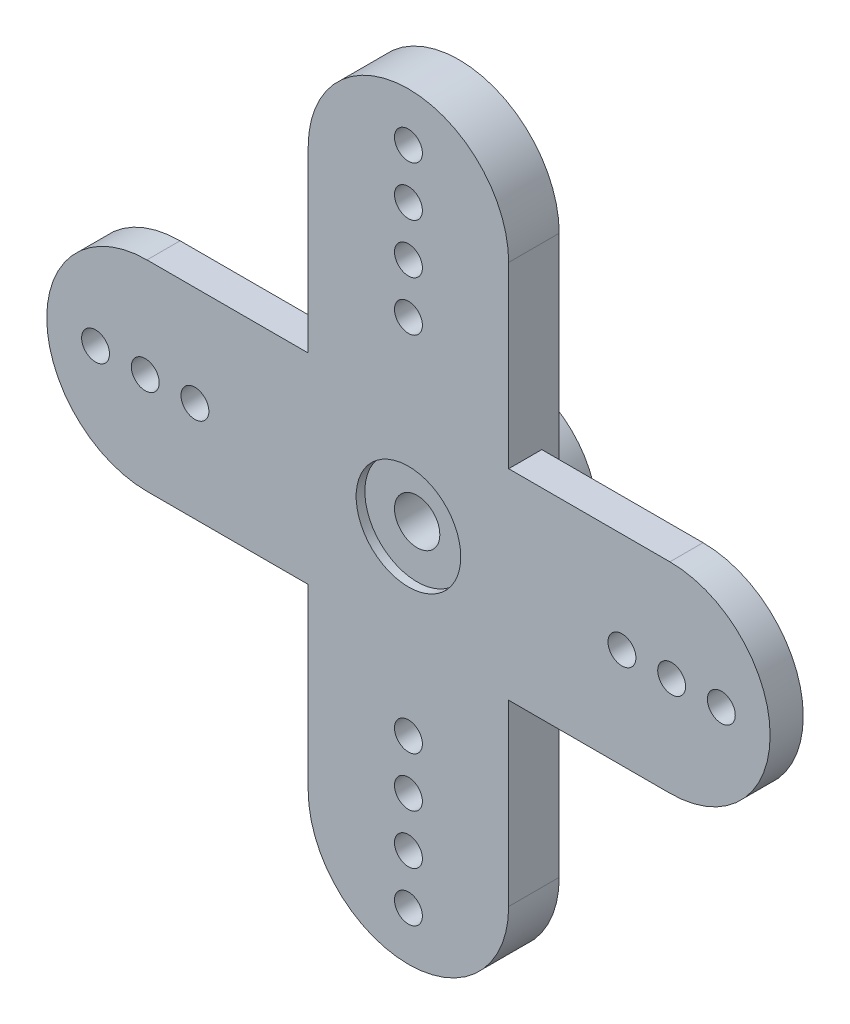
from build123d import *

# Parameters (mm, degrees)
BOSS_EXTRUDE1_DEPTH = 1.9
BOSS_EXTRUDE2_DEPTH = 1
SKETCH3_R           = 3
CUT_EXTRUDE1_DEPTH  = 0.5
SKETCH4_R           = 4.825
SKETCH4_R_2         = 2.775
BOSS_EXTRUDE3_DEPTH = 3.1
SKETCH5_R           = 1.3
CUT_EXTRUDE2_DEPTH  = 3.9
SKETCH6_R           = 0.8
CUT_EXTRUDE4_DEPTH  = 7


with BuildPart() as part:
    # Sketch1 → Boss-Extrude1 (new body)
    with BuildSketch(Plane.XY):
        with BuildLine():
            Line((-5.75, 16), (-5.75, 5.75))
            Line((-5.75, 5.75), (-15, 5.75))
            ThreePointArc((-15, 5.75), (-20.75, 0), (-15, -5.75))
            Line((-15, -5.75), (-5.75, -5.75))
            Line((-5.75, -5.75), (-5.75, -16))
            ThreePointArc((-5.75, -16), (0, -21.75), (5.75, -16))
            Line((5.75, -16), (5.75, -5.75))
            Line((5.75, -5.75), (15, -5.75))
            ThreePointArc((15, -5.75), (20.75, 0), (15, 5.75))
            Line((15, 5.75), (5.75, 5.75))
            Line((5.75, 5.75), (5.75, 16))
            ThreePointArc((5.75, 16), (0, 21.75), (-5.75, 16))
        make_face()
    extrude(amount=BOSS_EXTRUDE1_DEPTH)

    # Sketch2 → Boss-Extrude2 (add)
    with BuildSketch(Plane(origin=(0, 0, 0), x_dir=(-1, 0, 0), z_dir=(0, 0, -1))):
        with BuildLine():
            Line((-5.75, 16), (-5.75, -16))
            ThreePointArc((-5.75, -16), (0, -21.75), (5.75, -16))
            Line((5.75, -16), (5.75, -5.75))
            Line((5.75, -5.75), (5.75, 5.75))
            Line((5.75, 5.75), (5.75, 16))
            ThreePointArc((5.75, 16), (0, 21.75), (-5.75, 16))
        make_face()
    extrude(amount=BOSS_EXTRUDE2_DEPTH)

    # Sketch3 → Cut-Extrude1 (cut)
    with BuildSketch(Plane.XY.offset(1.9)):
        Circle(SKETCH3_R)
    extrude(amount=-CUT_EXTRUDE1_DEPTH, mode=Mode.SUBTRACT)

    # Sketch4 → Boss-Extrude3 (add)
    with BuildSketch(Plane(origin=(0, 0, -1), x_dir=(-1, 0, 0), z_dir=(0, 0, -1))):
        Circle(SKETCH4_R)
        Circle(SKETCH4_R_2, mode=Mode.SUBTRACT)
    extrude(amount=BOSS_EXTRUDE3_DEPTH)

    # Sketch5 → Cut-Extrude2 (cut, through all)
    with BuildSketch(Plane(origin=(0, 0, -1), x_dir=(-1, 0, 0), z_dir=(0, 0, -1))):
        Circle(SKETCH5_R)
    extrude(amount=-CUT_EXTRUDE2_DEPTH, mode=Mode.SUBTRACT)

    # Sketch6 → Cut-Extrude4 (cut, through all)
    with BuildSketch(Plane.XY.offset(1.9)):
        with Locations((-17.95, 0)):
            Circle(SKETCH6_R)
        with Locations((-15.1, 0)):
            Circle(SKETCH6_R)
        with Locations((-12.25, 0)):
            Circle(SKETCH6_R)
        with Locations((0, 18.95)):
            Circle(SKETCH6_R)
        with Locations((0, 16.1)):
            Circle(SKETCH6_R)
        with Locations((0, 13.25)):
            Circle(SKETCH6_R)
        with Locations((12.25, 0)):
            Circle(SKETCH6_R)
        with Locations((15.1, 0)):
            Circle(SKETCH6_R)
        with Locations((17.95, 0)):
            Circle(SKETCH6_R)
        with Locations((0, -10.4)):
            Circle(SKETCH6_R)
        with Locations((0, -13.25)):
            Circle(SKETCH6_R)
        with Locations((0, -16.1)):
            Circle(SKETCH6_R)
        with Locations((0, -18.95)):
            Circle(SKETCH6_R)
        with Locations((0, 10.4)):
            Circle(SKETCH6_R)
    extrude(amount=-CUT_EXTRUDE4_DEPTH, mode=Mode.SUBTRACT)


solid = part.part
